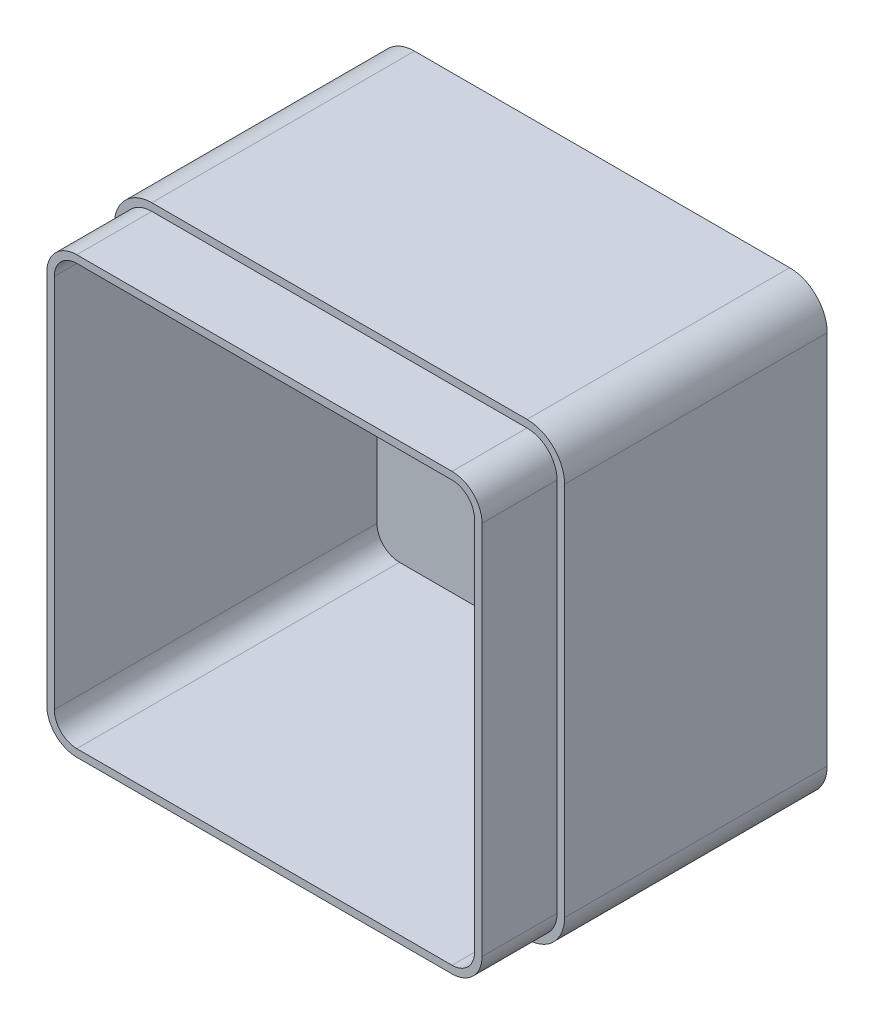
from build123d import *

# Parameters (mm, degrees)
SKETCH3_W           = 120
SKETCH3_H           = 120
BOSS_EXTRUDE1_DEPTH = 90
FILLET1_R           = 10
SHELL1_T            = -4
CUT_EXTRUDE1_DEPTH  = 20


with BuildPart() as part:
    # Sketch3 → Boss-Extrude1 (new body)
    with BuildSketch(Plane.XY):
        with Locations((60, 60)):
            Rectangle(SKETCH3_W, SKETCH3_H)
    extrude(amount=BOSS_EXTRUDE1_DEPTH)

    # Fillet1
    fillet1_edges = [part.edges().sort_by_distance(p)[0] for p in [
        (0, 120, 45),
        (120, 120, 45),
        (120, 0, 45),
        (0, 0, 45),
    ]]
    fillet(fillet1_edges, radius=FILLET1_R)

    # Shell1
    shell1_openings = [part.faces().sort_by_distance(p)[0] for p in [
        (60, 60, 90),
    ]]
    offset(amount=SHELL1_T, openings=shell1_openings, kind=Kind.INTERSECTION)

    # Sketch4 → Cut-Extrude1 (cut)
    with BuildSketch(Plane.XY.offset(90)):
        with BuildLine():
            Line((10, 0), (110, 0))
            ThreePointArc((110, 0), (117.071067812, 2.928932188), (120, 10))
            Line((120, 10), (120, 110))
            ThreePointArc((120, 110), (117.071067812, 117.071067812), (110, 120))
            Line((110, 120), (10, 120))
            ThreePointArc((10, 120), (2.928932188, 117.071067812), (0, 110))
            Line((0, 110), (0, 10))
            ThreePointArc((0, 10), (2.928932188, 2.928932188), (10, 0))
        make_face()
        with BuildLine():
            Line((10, 2), (110, 2))
            ThreePointArc((110, 2), (115.656854249, 4.343145751), (118, 10))
            Line((118, 10), (118, 110))
            ThreePointArc((118, 110), (115.656854249, 115.656854249), (110, 118))
            Line((110, 118), (10, 118))
            ThreePointArc((10, 118), (4.343145751, 115.656854249), (2, 110))
            Line((2, 110), (2, 10))
            ThreePointArc((2, 10), (4.343145751, 4.343145751), (10, 2))
        make_face(mode=Mode.SUBTRACT)
    extrude(amount=-CUT_EXTRUDE1_DEPTH, mode=Mode.SUBTRACT)


solid = part.part
